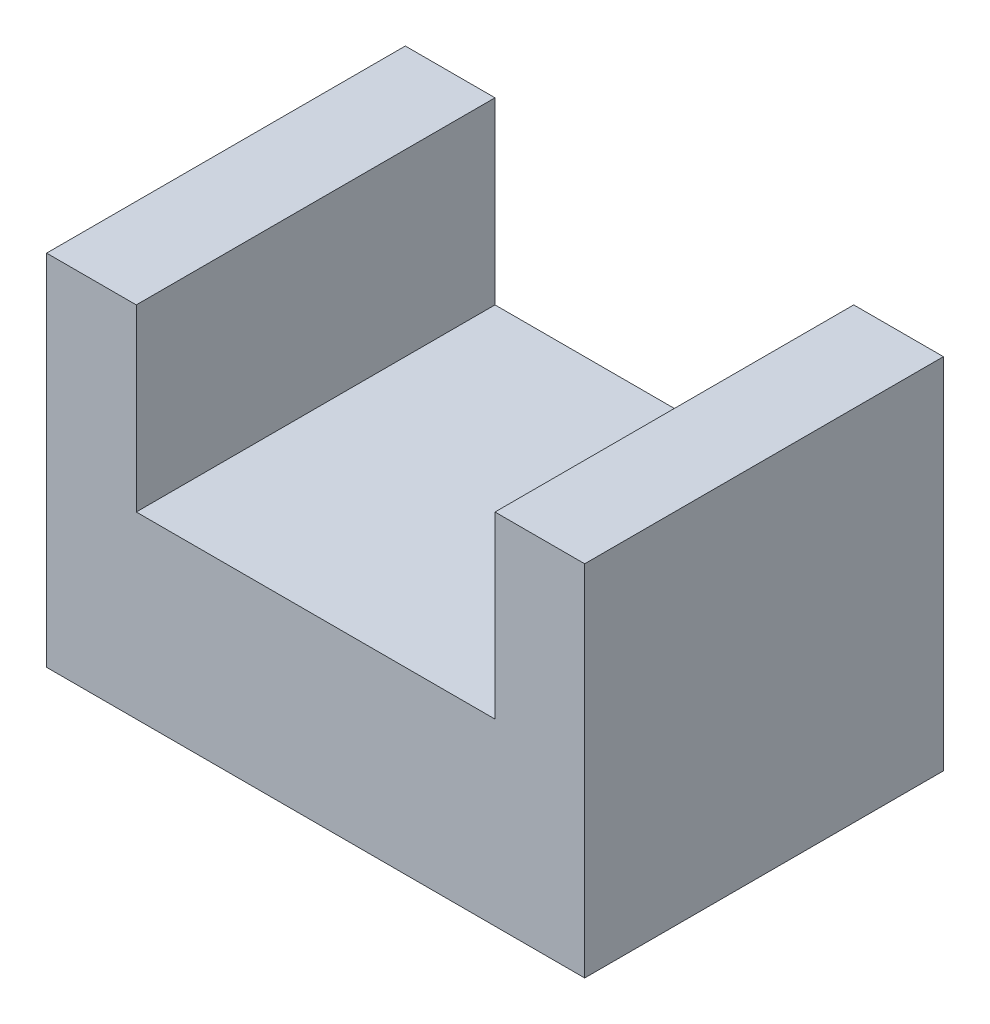
from build123d import *

# Parameters (mm, degrees)
BOSS_EXTRUDE1_DEPTH = 50.8


with BuildPart() as part:
    # Sketch1 → Boss-Extrude1 (new body)
    with BuildSketch(Plane.XY):
        Polygon((-43.523678647, 33.938266385), (-43.523678647, -16.861733615), (32.676321353, -16.861733615), (32.676321353, 33.938266385), (19.976321353, 33.938266385), (19.976321353, 8.538266385), (-30.823678647, 8.538266385), (-30.823678647, 33.938266385), align=None)
    extrude(amount=BOSS_EXTRUDE1_DEPTH)


solid = part.part
